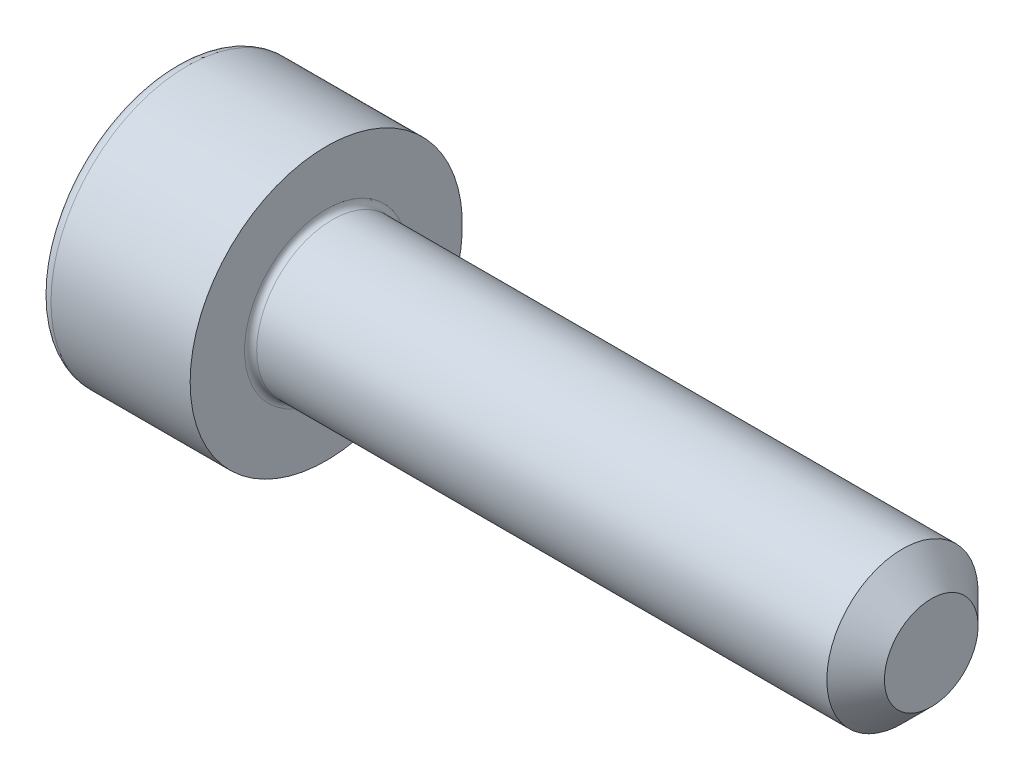
from build123d import *

# Parameters (mm, degrees)
FILLET1_R   = 0.1
FILLET2_R   = 0.2
HEX_2_DEPTH = 1


with BuildPart() as part:
    # BodySke → Base-Revolve (revolve)
    with BuildSketch(Plane.XY):
        Polygon((0, 0), (0, 2.25), (2.5, 2.25), (2.5, 1.25), (12.024, 1.25), (12.5, 0.774), (12.5, 0), align=None)
    revolve(axis=Axis((-31.75, 0, 0), (1, 0, 0)))

    # Fillet1
    fillet1_edges = [part.edges().sort_by_distance(p)[0] for p in [
        (2.5, -1.25, 0),
    ]]
    fillet(fillet1_edges, radius=FILLET1_R)

    # Fillet2
    fillet2_edges = [part.edges().sort_by_distance(p)[0] for p in [
        (0, -2.25, 0),
    ]]
    fillet(fillet2_edges, radius=FILLET2_R)

    # Sketch2 → Hex-PreBroach (revolve, cut)
    with BuildSketch(Plane.XY):
        Polygon((0, 0.76), (1, 0.76), (1.438786205, 0), (0, 0), align=None)
    revolve(axis=Axis((0, 0, 0), (1, 0, 0)), mode=Mode.SUBTRACT)

    # Sketch3 → Hex 2 (cut)
    with BuildSketch(Plane(origin=(0, 0, 0), x_dir=(0, 0.5, 0.866025404), z_dir=(-1, 0, 0))):
        Polygon((0.438786205, 0.76), (-0.438786205, 0.76), (-0.877572409, 0), (-0.438786205, -0.76), (0.438786205, -0.76), (0.877572409, 0), align=None)
    extrude(amount=-HEX_2_DEPTH, mode=Mode.SUBTRACT)


solid = part.part
